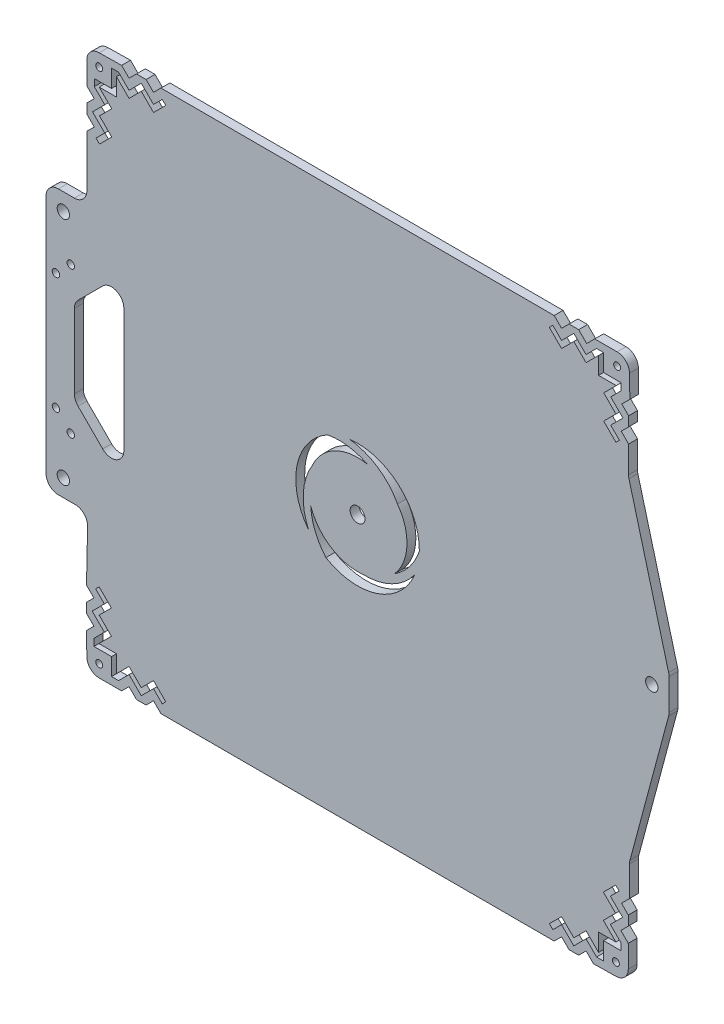
from build123d import *

# Parameters (mm, degrees)
MODEL_R             = 2.5
MODEL_R_2           = 1.4
MODEL_R_3           = 3
MODEL_R_4           = 1.5
BOSS_EXTRUDE1_DEPTH = 3.6


with BuildPart() as part:
    # Model → Boss-Extrude1 (new body)
    with BuildSketch(Plane.XY):
        with BuildLine():
            Line((-4, 125.6), (2.5, 125.6))
            ThreePointArc((2.5, 125.6), (6.035533906, 127.064466094), (7.5, 130.6))
            Line((7.5, 130.6), (7.5, 151.529437252))
            Line((7.5, 151.529437252), (10.5, 154.529437252))
            Line((10.5, 154.529437252), (7.5, 157.529437252))
            Line((7.5, 157.529437252), (7.5, 161.428932188))
            Line((7.5, 161.428932188), (10.5, 164.428932188))
            Line((10.5, 164.428932188), (7.5, 167.428932188))
            Line((7.5, 167.428932188), (7.5, 176.5))
            ThreePointArc((7.5, 176.5), (8.964466094, 180.035533906), (12.5, 181.5))
            Line((12.5, 181.5), (21.571067812, 181.642135624))
            Line((21.571067812, 181.642135624), (24.571067812, 178.642135624))
            Line((24.571067812, 178.642135624), (27.571067812, 181.642135624))
            Line((27.571067812, 181.642135624), (31.470562748, 181.642135624))
            Line((31.470562748, 181.642135624), (34.470562748, 178.642135624))
            Line((34.470562748, 178.642135624), (37.470562748, 181.642135624))
            Line((37.470562748, 181.642135624), (196.529437252, 181.5))
            Line((196.529437252, 181.5), (199.529437252, 178.5))
            Line((199.529437252, 178.5), (202.529437252, 181.5))
            Line((202.529437252, 181.5), (206.428932188, 181.5))
            Line((206.428932188, 181.5), (209.678932188, 178.25))
            Line((209.678932188, 178.25), (212.928932188, 181.5))
            Line((212.928932188, 181.5), (222, 181.5))
            ThreePointArc((222, 181.5), (225.535533906, 180.035533906), (227, 176.5))
            Line((227, 176.5), (227.142135624, 167.428932188))
            Line((227.142135624, 167.428932188), (223.892135624, 164.178932188))
            Line((223.892135624, 164.178932188), (226.642135624, 161.428932188))
            Line((226.642135624, 161.428932188), (226.642135624, 157.529437252))
            Line((226.642135624, 157.529437252), (223.642135624, 154.529437252))
            Line((223.642135624, 154.529437252), (226.642135624, 151.529437252))
            Line((226.642135624, 151.529437252), (226.618371675, 140.74062704))
            ThreePointArc((226.618371675, 140.74062704), (226.660419488, 140.082442762), (226.788730414, 139.435518602))
            Line((226.788730414, 139.435518602), (242.829629131, 79.570069589))
            ThreePointArc((242.829629131, 79.570069589), (242.957224307, 78.928605325), (243, 78.275974364))
            Line((243, 78.275974364), (243, 74))
            Line((243, 74), (243, 65.658262488))
            ThreePointArc((243, 65.658262488), (242.957224307, 65.005631527), (242.829629131, 64.364167262))
            Line((242.829629131, 64.364167262), (227.170370869, 5.923019816))
            ThreePointArc((227.170370869, 5.923019816), (227.042775693, 5.281555552), (227, 4.628924591))
            Line((227, 4.628924591), (227, -7.529437252))
            Line((227, -7.529437252), (223.75, -10.779437252))
            Line((223.75, -10.779437252), (226.5, -13.529437252))
            Line((226.5, -13.529437252), (226.5, -17.428932188))
            Line((226.5, -17.428932188), (223.5, -20.428932188))
            Line((223.5, -20.428932188), (226.5, -23.428932188))
            Line((226.5, -23.428932188), (226.5, -32.5))
            ThreePointArc((226.5, -32.5), (225.035533906, -36.035533906), (221.5, -37.5))
            Line((221.5, -37.5), (212.428932188, -37.642135624))
            Line((212.428932188, -37.642135624), (209.428932188, -34.642135624))
            Line((209.428932188, -34.642135624), (206.428932188, -37.642135624))
            Line((206.428932188, -37.642135624), (202.529437252, -37.642135624))
            Line((202.529437252, -37.642135624), (199.529437252, -34.642135624))
            Line((199.529437252, -34.642135624), (196.529437252, -37.642135624))
            Line((196.529437252, -37.642135624), (37.470562748, -37.5))
            Line((37.470562748, -37.5), (34.470562748, -34.5))
            Line((34.470562748, -34.5), (31.470562748, -37.5))
            Line((31.470562748, -37.5), (27.571067812, -37.5))
            Line((27.571067812, -37.5), (24.571067812, -34.5))
            Line((24.571067812, -34.5), (21.571067812, -37.5))
            Line((21.571067812, -37.5), (12.5, -37.5))
            ThreePointArc((12.5, -37.5), (8.964466094, -36.035533906), (7.5, -32.5))
            Line((7.5, -32.5), (7.357864376, -23.428932188))
            Line((7.357864376, -23.428932188), (10.357864376, -20.428932188))
            Line((10.357864376, -20.428932188), (7.357864376, -17.428932188))
            Line((7.357864376, -17.428932188), (7.357864376, -13.529437252))
            Line((7.357864376, -13.529437252), (10.357864376, -10.529437252))
            Line((10.357864376, -10.529437252), (7.357864376, -7.529437252))
            Line((7.357864376, -7.529437252), (7.811096687, 13.291183609))
            ThreePointArc((7.811096687, 13.291183609), (6.386080164, 16.896849871), (2.812280928, 18.4))
            Line((2.812280928, 18.4), (-4, 18.4))
            ThreePointArc((-4, 18.4), (-7.535533906, 19.864466094), (-9, 23.4))
            Line((-9, 23.4), (-9, 120.6))
            ThreePointArc((-9, 120.6), (-7.535533906, 124.135533906), (-4, 125.6))
        make_face()
        with Locations((-2, 118.6)):
            Circle(MODEL_R, mode=Mode.SUBTRACT)
        with Locations((-2, 25.4)):
            Circle(MODEL_R, mode=Mode.SUBTRACT)
        with Locations((236, 72)):
            Circle(MODEL_R, mode=Mode.SUBTRACT)
        with Locations((12.5, 176.5)):
            Circle(MODEL_R_2, mode=Mode.SUBTRACT)
        with Locations((117, 72)):
            Circle(MODEL_R_3, mode=Mode.SUBTRACT)
        with Locations((-5, 95.6)):
            Circle(MODEL_R_4, mode=Mode.SUBTRACT)
        with Locations((1, 101.6)):
            Circle(MODEL_R_4, mode=Mode.SUBTRACT)
        with Locations((12.5, -32.5)):
            Circle(MODEL_R_2, mode=Mode.SUBTRACT)
        with Locations((221.5, -32.5)):
            Circle(MODEL_R_2, mode=Mode.SUBTRACT)
        with Locations((222, 176.5)):
            Circle(MODEL_R_2, mode=Mode.SUBTRACT)
        with Locations((-5, 48.4)):
            Circle(MODEL_R_4, mode=Mode.SUBTRACT)
        with Locations((1, 42.4)):
            Circle(MODEL_R_4, mode=Mode.SUBTRACT)
        with BuildLine():
            Line((3.922835534, 90.535533906), (13.922835534, 100.535533906))
            ThreePointArc((13.922835534, 100.535533906), (19.371786601, 101.619397663), (22.45836944, 97))
            Line((22.45836944, 97), (22.45836944, 47))
            ThreePointArc((22.45836944, 47), (19.371786601, 42.380602337), (13.922835534, 43.464466094))
            Line((13.922835534, 43.464466094), (3.922835534, 53.464466094))
            ThreePointArc((3.922835534, 53.464466094), (2.838971777, 55.086582838), (2.45836944, 57))
            Line((2.45836944, 57), (2.45836944, 87))
            ThreePointArc((2.45836944, 87), (2.838971777, 88.913417162), (3.922835534, 90.535533906))
        make_face(mode=Mode.SUBTRACT)
        Polygon((14.742640687, 154.529437252), (9.792893219, 159.47918472), (14.742640687, 164.428932188), (10.5, 168.671572875), (10.5, 171.5), (17.5, 171.5), (17.5, 178.642135624), (20.328427125, 178.642135624), (24.571067812, 174.399494937), (29.52081528, 179.349242405), (34.470562748, 174.399494937), (38.006096654, 177.935028843), (39.420310217, 176.52081528), (34.470562748, 171.571067812), (29.52081528, 176.52081528), (24.571067812, 171.571067812), (19.5, 176.642135624), (19.5, 169.5), (12.5, 169.5), (17.571067812, 164.428932188), (12.621320344, 159.47918472), (17.571067812, 154.529437252), (12.621320344, 149.579689783), (11.207106781, 150.993903346), align=None, mode=Mode.SUBTRACT)
        Polygon((34.470562748, -30.257359313), (29.52081528, -35.207106781), (24.571067812, -30.257359313), (20.328427125, -34.5), (17.5, -34.5), (17.5, -27.5), (10.357864376, -27.5), (10.357864376, -24.671572875), (14.600505063, -20.428932188), (9.650757595, -15.47918472), (14.600505063, -10.529437252), (11.064971157, -6.993903346), (12.47918472, -5.579689783), (17.428932188, -10.529437252), (12.47918472, -15.47918472), (17.428932188, -20.428932188), (12.357864376, -25.5), (19.5, -25.5), (19.5, -32.5), (24.571067812, -27.428932188), (29.52081528, -32.378679656), (34.470562748, -27.428932188), (39.420310217, -32.378679656), (38.006096654, -33.792893219), align=None, mode=Mode.SUBTRACT)
        Polygon((219.257359313, -10.529437252), (224.207106781, -15.47918472), (219.257359313, -20.428932188), (223.5, -24.671572875), (223.5, -27.5), (216.5, -27.5), (216.5, -34.642135624), (213.671572875, -34.642135624), (209.428932188, -30.399494937), (204.47918472, -35.349242405), (199.529437252, -30.399494937), (195.993903346, -33.935028843), (194.579689783, -32.52081528), (199.529437252, -27.571067812), (204.47918472, -32.52081528), (209.428932188, -27.571067812), (214.5, -32.642135624), (214.5, -25.5), (221.5, -25.5), (216.428932188, -20.428932188), (221.378679656, -15.47918472), (216.428932188, -10.529437252), (221.378679656, -5.579689783), (222.792893219, -6.993903346), align=None, mode=Mode.SUBTRACT)
        Polygon((199.529437252, 174.257359313), (204.47918472, 179.207106781), (209.428932188, 174.257359313), (213.671572875, 178.5), (216.5, 178.5), (216.5, 171.5), (223.642135624, 171.5), (223.642135624, 168.671572875), (219.399494937, 164.428932188), (224.349242405, 159.47918472), (219.399494937, 154.529437252), (222.935028843, 150.993903346), (221.52081528, 149.579689783), (216.571067812, 154.529437252), (221.52081528, 159.47918472), (216.571067812, 164.428932188), (221.642135624, 169.5), (214.5, 169.5), (214.5, 176.5), (209.428932188, 171.428932188), (204.47918472, 176.378679656), (199.529437252, 171.428932188), (194.579689783, 176.378679656), (195.993903346, 177.792893219), align=None, mode=Mode.SUBTRACT)
        with BuildLine():
            ThreePointArc((98.730744919, 80.138446951), (95.052641959, 68.621519903), (97.208949685, 56.725369811))
            ThreePointArc((97.208949685, 56.725369811), (92.508782682, 77.017995045), (104.810701222, 93.827070241))
            ThreePointArc((104.810701222, 93.827070241), (113.080779509, 94.070068861), (120.977277613, 91.600542411))
            ThreePointArc((120.977277613, 91.600542411), (107.839756386, 89.778918329), (98.730744919, 80.138446951))
        make_face(mode=Mode.SUBTRACT)
        with BuildLine():
            ThreePointArc((98.036793538, 65.644152246), (99.846369949, 57.570821061), (104.19185207, 50.530222484))
            ThreePointArc((104.19185207, 50.530222484), (124.899897474, 48.28098611), (140.123742935, 62.497762754))
            ThreePointArc((140.123742935, 62.497762754), (130.899528611, 54.682270439), (119.086525733, 52.109137516))
            ThreePointArc((119.086525733, 52.109137516), (106.183126883, 55.177537161), (98.036793538, 65.644152246))
        make_face(mode=Mode.SUBTRACT)
        with BuildLine():
            ThreePointArc((131.985928849, 58.755305344), (138.072850542, 64.359110078), (141.997446708, 71.642707275))
            ThreePointArc((141.997446708, 71.642707275), (133.591319844, 90.701018845), (113.66730738, 96.776867435))
            ThreePointArc((113.66730738, 96.776867435), (125.04782943, 92.696209658), (133.182729348, 83.752415533))
            ThreePointArc((133.182729348, 83.752415533), (136.977116731, 71.04354451), (131.985928849, 58.755305344))
        make_face(mode=Mode.SUBTRACT)
    extrude(amount=BOSS_EXTRUDE1_DEPTH)


solid = part.part
